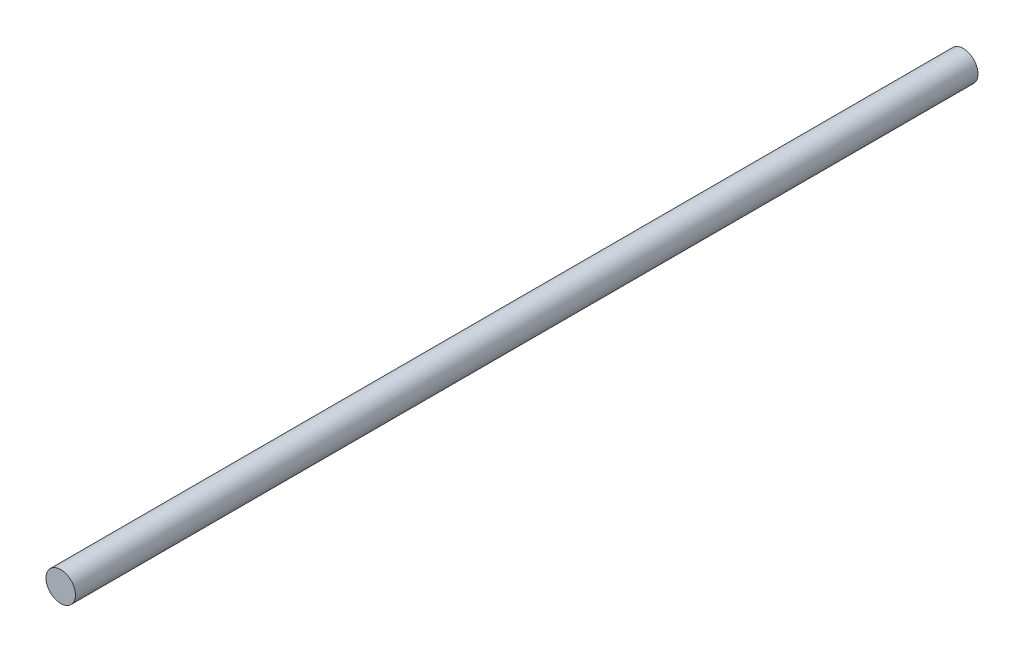
from build123d import *

# Parameters (mm, degrees)
SKETCH1_R           = 3.937
BOSS_EXTRUDE1_DEPTH = 241.3


with BuildPart() as part:
    # Sketch1 → Boss-Extrude1 (new body)
    with BuildSketch(Plane.XY):
        Circle(SKETCH1_R)
    extrude(amount=BOSS_EXTRUDE1_DEPTH)


solid = part.part
